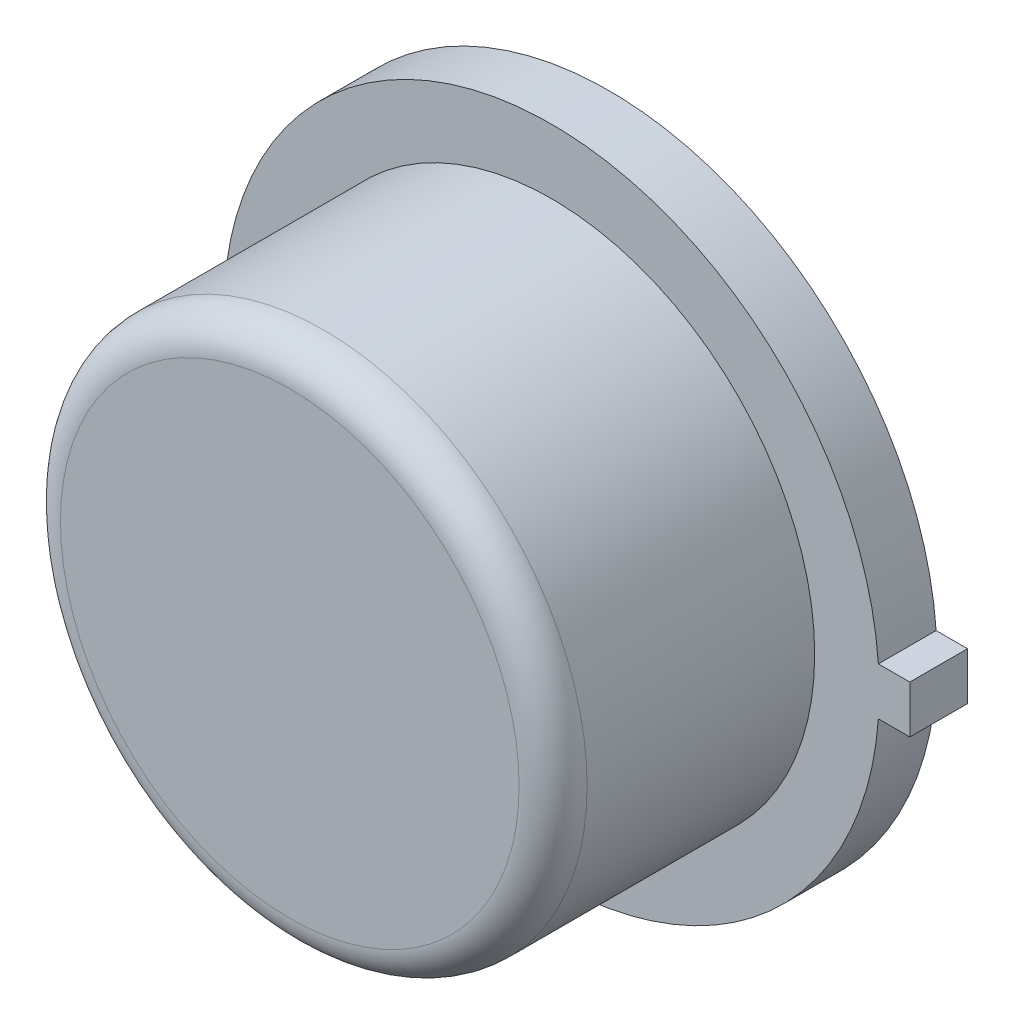
from build123d import *

# Parameters (mm, degrees)
BOSS_EXTRUDE1_DEPTH = 0.4318
SKETCH2_R           = 1.9685
BOSS_EXTRUDE2_DEPTH = 1.9558
SKETCH3_R           = 1.757566481
BOSS_EXTRUDE3_DEPTH = 0.00254
FILLET1_R           = 0.254


with BuildPart() as part:
    # Sketch1 → Boss-Extrude1 (new body)
    with BuildSketch(Plane.XY):
        with BuildLine():
            Line((2.6797, 0.1778), (2.4511, 0.1778))
            Line((2.4511, 0.1778), (2.44464279, 0.1778))
            ThreePointArc((2.44464279, 0.1778), (-2.4511, 0), (2.44464279, -0.1778))
            Line((2.44464279, -0.1778), (2.4511, -0.1778))
            Line((2.4511, -0.1778), (2.6797, -0.1778))
            Line((2.6797, -0.1778), (2.6797, 0.1778))
        make_face()
    extrude(amount=BOSS_EXTRUDE1_DEPTH)

    # Sketch2 → Boss-Extrude2 (add)
    with BuildSketch(Plane.XY.offset(0.4318)):
        Circle(SKETCH2_R)
    extrude(amount=BOSS_EXTRUDE2_DEPTH)

    # Sketch3 → Boss-Extrude3 (add)
    with BuildSketch(Plane(origin=(0, 0, 0), x_dir=(-1, 0, 0), z_dir=(0, 0, -1))):
        Circle(SKETCH3_R)
    extrude(amount=BOSS_EXTRUDE3_DEPTH)

    # Fillet1
    fillet1_edges = [part.edges().sort_by_distance(p)[0] for p in [
        (-1.9685, 0, 2.3876),
    ]]
    fillet(fillet1_edges, radius=FILLET1_R)


solid = part.part
